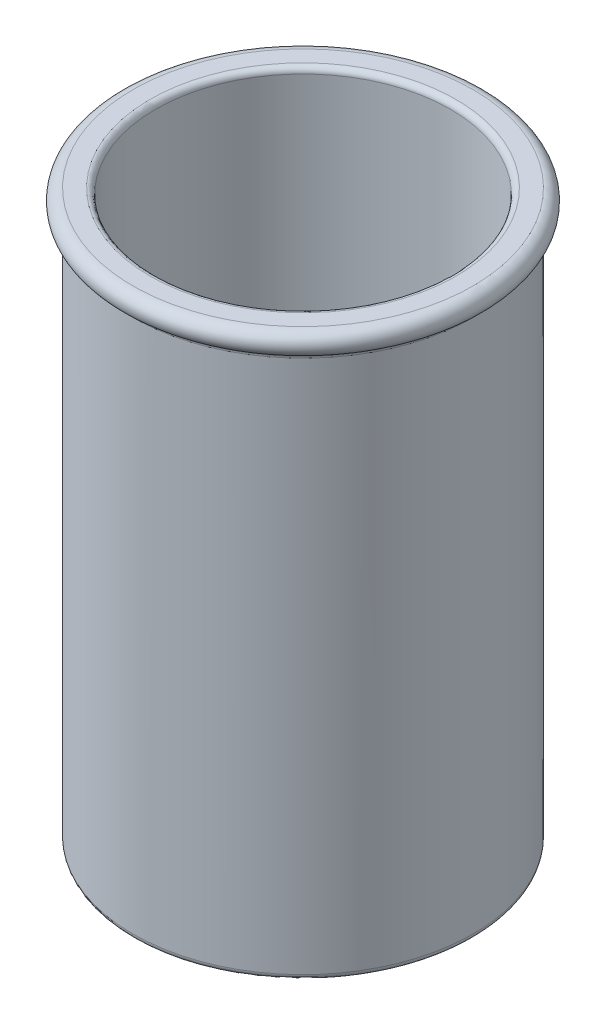
from build123d import *

# Parameters (mm, degrees)
BASE_R              = 15
BOSS_EXTRUDE1_DEPTH = 2
SKETCH2_R           = 15
SKETCH2_R_2         = 13
BOSS_EXTRUDE2_DEPTH = 48
FILLET1_R           = 0.5
FILLET2_R           = 0.5
FILLET4_R           = 0.5


with BuildPart() as part:
    # Base → Boss-Extrude1 (new body)
    with BuildSketch(Plane(origin=(0, 0, 0), x_dir=(1, 0, 0), z_dir=(0, 1, 0))):
        Circle(BASE_R)
    extrude(amount=BOSS_EXTRUDE1_DEPTH)

    # Sketch2 → Boss-Extrude2 (add)
    with BuildSketch(Plane(origin=(0, 2, 0), x_dir=(1, 0, 0), z_dir=(0, 1, 0))):
        Circle(SKETCH2_R)
        Circle(SKETCH2_R_2, mode=Mode.SUBTRACT)
    extrude(amount=BOSS_EXTRUDE2_DEPTH)

    # Sketch4 → Revolve3 (revolve)
    with BuildSketch(Plane.XY):
        with BuildLine():
            Line((15, 50), (15, 48))
            ThreePointArc((15, 48), (16, 49), (15, 50))
        make_face()
    revolve(axis=Axis((0, 0, 0), (0, 1, 0)))

    # Fillet1
    fillet1_edges = [part.edges().sort_by_distance(p)[0] for p in [
        (-15, 0, 0),
    ]]
    fillet(fillet1_edges, radius=FILLET1_R)

    # Fillet2
    fillet2_edges = [part.edges().sort_by_distance(p)[0] for p in [
        (-13, 50, 0),
    ]]
    fillet(fillet2_edges, radius=FILLET2_R)

    # Fillet4
    fillet4_edges = [part.edges().sort_by_distance(p)[0] for p in [
        (-15, 48, 0),
    ]]
    fillet(fillet4_edges, radius=FILLET4_R)


solid = part.part
